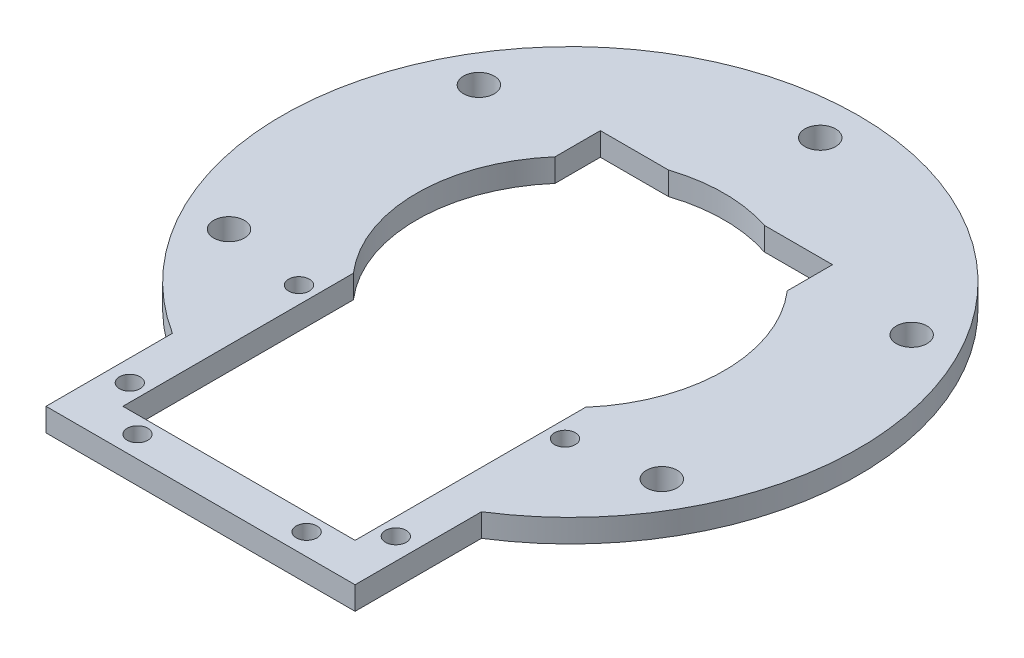
from build123d import *

# Parameters (mm, degrees)
SKETCH1_R           = 37.5
SKETCH1_R_2         = 2
BOSS_EXTRUDE1_DEPTH = 3
SKETCH2_R           = 1.35
BOSS_EXTRUDE2_DEPTH = 3
SKETCH2_3_R         = 2
SKETCH2_3_R_2       = 1.35
CUT_EXTRUDE1_DEPTH  = 4
SKETCH3_R           = 20
CUT_EXTRUDE2_DEPTH  = 4


with BuildPart() as part:
    # Sketch1 → Boss-Extrude1 (new body)
    with BuildSketch(Plane(origin=(0, 0, 0), x_dir=(1, 0, 0), z_dir=(0, 1, 0))):
        Circle(SKETCH1_R)
        with Locations((0, 32.5)):
            Circle(SKETCH1_R_2, mode=Mode.SUBTRACT)
        with Locations((28.145825623, 16.25)):
            Circle(SKETCH1_R_2, mode=Mode.SUBTRACT)
        with Locations((28.145825623, -16.25)):
            Circle(SKETCH1_R_2, mode=Mode.SUBTRACT)
        with Locations((0, -32.5)):
            Circle(SKETCH1_R_2, mode=Mode.SUBTRACT)
        with Locations((-28.145825623, -16.25)):
            Circle(SKETCH1_R_2, mode=Mode.SUBTRACT)
        with Locations((-28.145825623, 16.25)):
            Circle(SKETCH1_R_2, mode=Mode.SUBTRACT)
    extrude(amount=BOSS_EXTRUDE1_DEPTH)

    # Sketch2 → Boss-Extrude2 (add, through all)
    with BuildSketch(Plane(origin=(0, 3, 0), x_dir=(1, 0, 0), z_dir=(0, 1, 0))):
        with BuildLine():
            ThreePointArc((-15.1, -34.325500725), (-17.650457715, -33.086422328), (-20.1, -31.6581743))
            Line((-20.1, -31.6581743), (-20.1, -48.1))
            Line((-20.1, -48.1), (20.1, -48.1))
            Line((20.1, -48.1), (20.1, -31.6581743))
            ThreePointArc((20.1, -31.6581743), (17.650457715, -33.086422328), (15.1, -34.325500725))
            Line((15.1, -34.325500725), (15.1, -43.1))
            Line((15.1, -43.1), (-15.1, -43.1))
            Line((-15.1, -43.1), (-15.1, -34.325500725))
        make_face()
        with Locations((-11, -45.3)):
            Circle(SKETCH2_R, mode=Mode.SUBTRACT)
        with Locations((-17.3, -40)):
            Circle(SKETCH2_R, mode=Mode.SUBTRACT)
        with Locations((11, -45.3)):
            Circle(SKETCH2_R, mode=Mode.SUBTRACT)
        with Locations((17.3, -40)):
            Circle(SKETCH2_R, mode=Mode.SUBTRACT)
    extrude(amount=-BOSS_EXTRUDE2_DEPTH)

    # Sketch2_3 → Cut-Extrude1 (cut, through all)
    with BuildSketch(Plane(origin=(0, 3, 0), x_dir=(1, 0, 0), z_dir=(0, 1, 0))):
        with BuildLine():
            Line((15.1, 19), (-15.1, 19))
            Line((-15.1, 19), (-15.1, -34.325500725))
            ThreePointArc((-15.1, -34.325500725), (0, -37.5), (15.1, -34.325500725))
            Line((15.1, -34.325500725), (15.1, 19))
        make_face()
        with Locations((0, -32.5)):
            Circle(SKETCH2_3_R, mode=Mode.SUBTRACT)
        with Locations((-17.3, 4)):
            Circle(SKETCH2_3_R_2)
        with Locations((-17.3, -18)):
            Circle(SKETCH2_3_R_2)
        with Locations((17.3, -18)):
            Circle(SKETCH2_3_R_2)
        with Locations((17.3, 4)):
            Circle(SKETCH2_3_R_2)
    extrude(amount=-CUT_EXTRUDE1_DEPTH, mode=Mode.SUBTRACT)

    # Sketch3 → Cut-Extrude2 (cut, through all)
    with BuildSketch(Plane(origin=(0, 3, 0), x_dir=(1, 0, 0), z_dir=(0, 1, 0))):
        Circle(SKETCH3_R)
    extrude(amount=-CUT_EXTRUDE2_DEPTH, mode=Mode.SUBTRACT)


solid = part.part
